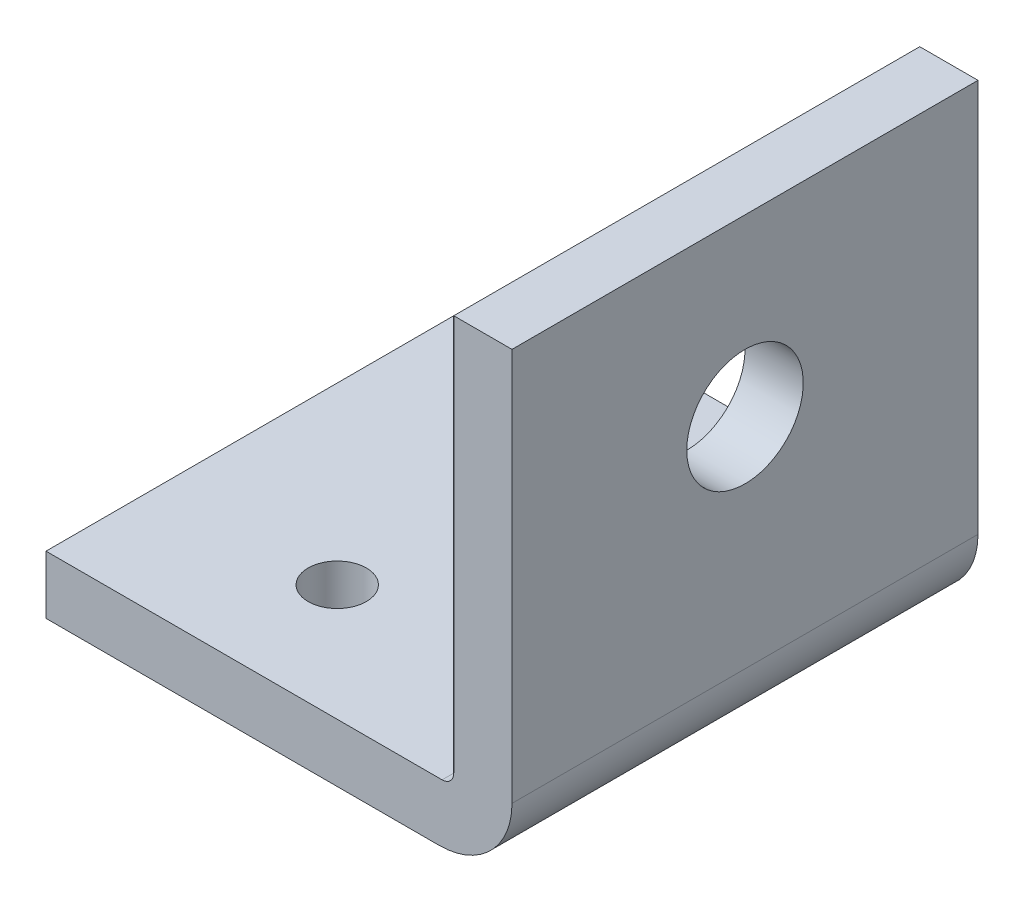
from build123d import *

# Parameters (mm, degrees)
BOSS_EXTRUDE1_DEPTH = 40
SKETCH3_R           = 2.5
CUT_EXTRUDE1_DEPTH  = 6
SKETCH4_R           = 5
CUT_EXTRUDE2_DEPTH  = 6
FILLET1_R           = 1


with BuildPart() as part:
    # Sketch1 → Boss-Extrude1 (new body)
    with BuildSketch(Plane.XY):
        with BuildLine():
            Line((0, 0), (0, 5))
            Line((0, 5), (35, 5))
            Line((35, 5), (35, 40))
            Line((35, 40), (40, 40))
            Line((40, 40), (40, 6.25))
            ThreePointArc((40, 6.25), (38.169417382, 1.830582618), (33.75, 0))
            Line((33.75, 0), (0, 0))
        make_face()
    extrude(amount=BOSS_EXTRUDE1_DEPTH)

    # Sketch3 → Cut-Extrude1 (cut, through all)
    with BuildSketch(Plane(origin=(0, 5, 0), x_dir=(1, 0, 0), z_dir=(0, 1, 0))):
        with Locations((15, -10)):
            Circle(SKETCH3_R)
        with Locations((15, -30)):
            Circle(SKETCH3_R)
    extrude(amount=-CUT_EXTRUDE1_DEPTH, mode=Mode.SUBTRACT)

    # Sketch4 → Cut-Extrude2 (cut, through all)
    with BuildSketch(Plane.ZY.offset(-35)):
        with Locations((20, 25)):
            Circle(SKETCH4_R)
    extrude(amount=-CUT_EXTRUDE2_DEPTH, mode=Mode.SUBTRACT)

    # Fillet1
    fillet1_edges = [part.edges().sort_by_distance(p)[0] for p in [
        (35, 5, 20),
    ]]
    fillet(fillet1_edges, radius=FILLET1_R)


solid = part.part
